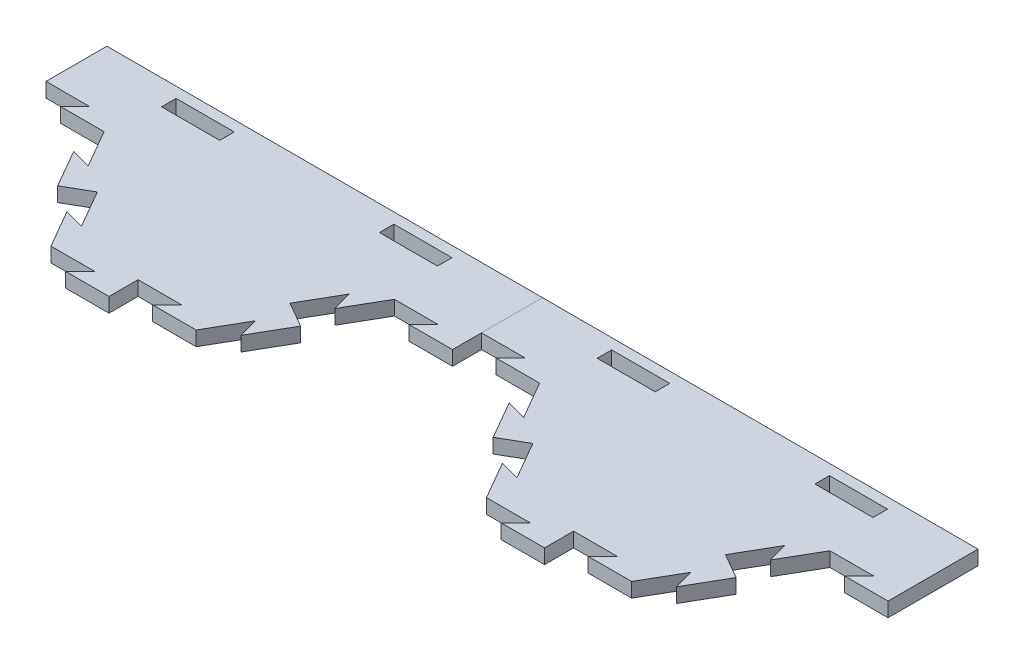
from build123d import *

# Parameters (mm, degrees)
BOSS_EXTRUDE1_DEPTH = 6.35
CUT_EXTRUDE4_DEPTH  = 7.35
BOSS_EXTRUDE4_DEPTH = 6.35
CIRPATTERN7_COUNT   = 6
SKETCH12_W          = 127
SKETCH12_H          = 61.34261314
CUT_EXTRUDE5_DEPTH  = 7.35
SKETCH13_W          = 190.5
SKETCH13_H          = 6.35
BOSS_EXTRUDE5_DEPTH = 32.995561898
CUT_EXTRUDE6_DEPTH  = 7.35
BOSS_EXTRUDE6_DEPTH = 6.35
SKETCH17_W          = 25.4
SKETCH17_H          = 6.35
CUT_EXTRUDE8_DEPTH  = 7.35
LPATTERN1_COUNT     = 2
LPATTERN1_PITCH     = 190.5


with BuildPart() as part:
    # Sketch1 → Boss-Extrude1 (new body)
    with BuildSketch(Plane(origin=(0, 0, 0), x_dir=(1, 0, 0), z_dir=(0, 1, 0))):
        Polygon((63.5, 0), (31.75, 54.99261314), (-31.75, 54.99261314), (-63.5, 0), (-31.75, -54.99261314), (31.75, -54.99261314), align=None)
    extrude(amount=-BOSS_EXTRUDE1_DEPTH)

    # Sketch10 → Cut-Extrude4 (cut, through all)
    with BuildSketch(Plane(origin=(0, 0, 0), x_dir=(1, 0, 0), z_dir=(0, 1, 0))):
        Polygon((41.275, 38.494829198), (32.600738686, 40.819090512), (42.125738686, 24.32130657), (47.625, 27.49630657), align=None)
    cut_extrude4 = extrude(amount=-CUT_EXTRUDE4_DEPTH, mode=Mode.SUBTRACT)

    # Sketch11 → Boss-Extrude4 (add)
    with BuildSketch(Plane(origin=(0, 0, 0), x_dir=(1, 0, 0), z_dir=(0, 1, 0))):
        Polygon((47.625, 27.49630657), (53.124261314, 30.67130657), (62.649261314, 14.173522628), (53.975, 16.497783942), align=None)
    boss_extrude4 = extrude(amount=-BOSS_EXTRUDE4_DEPTH)

    # CirPattern7: Cut-Extrude4, Boss-Extrude4 ×6 about axis
    cirpattern7_axis = Axis((0, 0, 0), (0, 1, 0))
    for i in range(1, CIRPATTERN7_COUNT):
        add(cut_extrude4.rotate(cirpattern7_axis, i * 360 / CIRPATTERN7_COUNT), mode=Mode.SUBTRACT)
        add(boss_extrude4.rotate(cirpattern7_axis, i * 360 / CIRPATTERN7_COUNT))

    # Sketch12 → Cut-Extrude5 (cut, through all)
    with BuildSketch(Plane(origin=(0, 0, 0), x_dir=(1, 0, 0), z_dir=(0, 1, 0))):
        with Locations((0, 30.67130657)):
            Rectangle(SKETCH12_W, SKETCH12_H)
    extrude(amount=-CUT_EXTRUDE5_DEPTH, mode=Mode.SUBTRACT)

    # Sketch13 → Boss-Extrude5 (add)
    with BuildSketch(Plane(origin=(0, 0, 0), x_dir=(-1, 0, 0), z_dir=(0, 0, -1))):
        with Locations((0, -3.175)):
            Rectangle(SKETCH13_W, SKETCH13_H)
    extrude(amount=BOSS_EXTRUDE5_DEPTH)

    # Sketch15 → Cut-Extrude6 (cut, through all)
    with BuildSketch(Plane(origin=(0, 0, 0), x_dir=(1, 0, 0), z_dir=(0, 1, 0))):
        Polygon((-82.55, 0), (-76.2, 6.35), (-95.25, 6.35), (-95.25, 0), align=None)
    extrude(amount=-CUT_EXTRUDE6_DEPTH, mode=Mode.SUBTRACT)

    # Sketch16 → Boss-Extrude6 (add)
    with BuildSketch(Plane(origin=(0, 0, 0), x_dir=(1, 0, 0), z_dir=(0, 1, 0))):
        Polygon((82.55, 0), (76.2, -6.35), (95.25, -6.35), (95.25, 0), align=None)
    extrude(amount=-BOSS_EXTRUDE6_DEPTH)

    # Sketch17 → Cut-Extrude8 (cut, through all)
    with BuildSketch(Plane(origin=(0, 0, 0), x_dir=(1, 0, 0), z_dir=(0, 1, 0))):
        with Locations((-47.625, 25.172035635)):
            Rectangle(SKETCH17_W, SKETCH17_H)
        with Locations((47.625, 25.172035635)):
            Rectangle(SKETCH17_W, SKETCH17_H)
    extrude(amount=-CUT_EXTRUDE8_DEPTH, mode=Mode.SUBTRACT)


with BuildPart() as lpattern1_1:
    # LPattern1: pattern copy
    add(part.part.moved(Location(Vector(1, 0, 0) * (1 * LPATTERN1_PITCH))))


solid = Compound([part.part, lpattern1_1.part])
